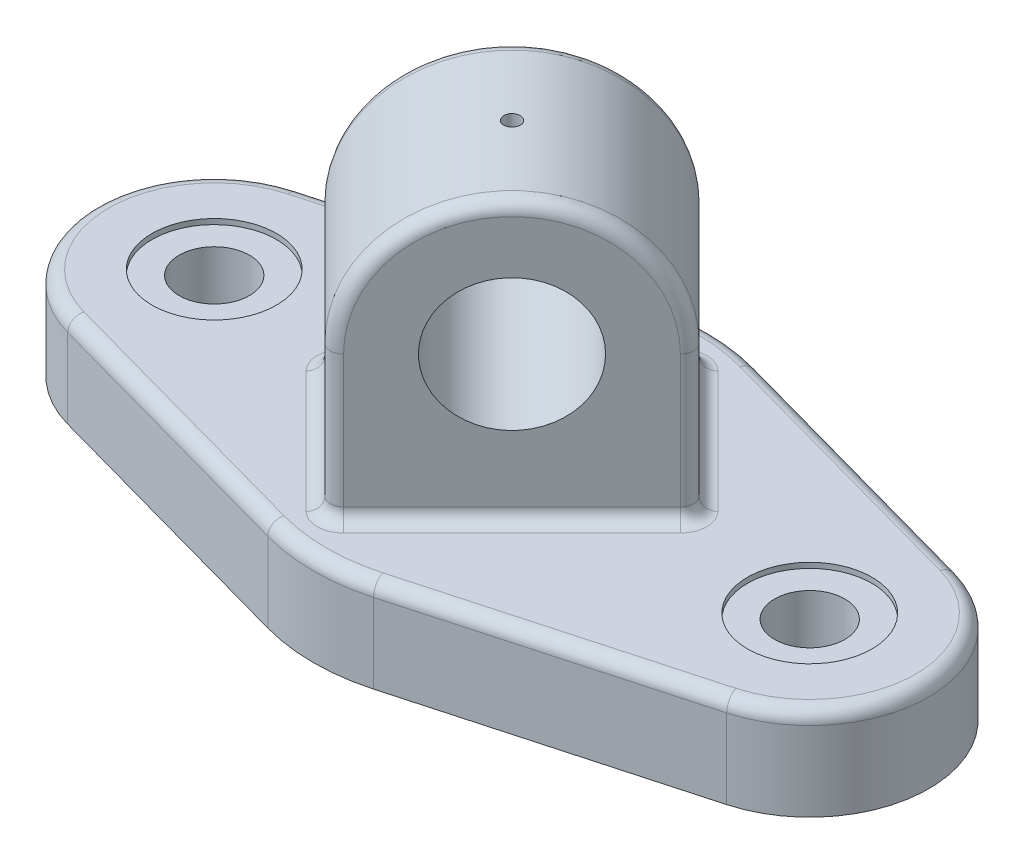
from build123d import *

# Parameters (mm, degrees)
BOSS_EXTRUDE1_DEPTH                                 = 17.78
CBORE_FOR_00_BINDING_HEAD_MACHINE_SCREW_D           = 13.4874
CBORE_FOR_00_BINDING_HEAD_MACHINE_SCREW_CBORE_D     = 23.876
CBORE_FOR_00_BINDING_HEAD_MACHINE_SCREW_CBORE_DEPTH = 1.016
SKETCH4_R                                           = 12.7
BOSS_EXTRUDE2_DEPTH                                 = 19.05
F_1_8_0_125_DIAMETER_HOLE1_REACH                    = 115.628
F_1_8_0_125_DIAMETER_HOLE1_BORE_R                   = 1.5875
FILLET1_R                                           = 2.54


with BuildPart() as part:
    # Sketch1 → Boss-Extrude1 (new body)
    with BuildSketch(Plane(origin=(0, 0, 0), x_dir=(1, 0, 0), z_dir=(0, 1, 0))):
        with BuildLine():
            Line((63.246, 22.032212417), (10.16, 36.720354029))
            ThreePointArc((10.16, 36.720354029), (0, 38.1), (-10.16, 36.720354029))
            Line((-10.16, 36.720354029), (-63.246, 22.032212417))
            ThreePointArc((-63.246, 22.032212417), (-80.01, 0), (-63.246, -22.032212417))
            Line((-63.246, -22.032212417), (-10.16, -36.720354029))
            ThreePointArc((-10.16, -36.720354029), (0, -38.1), (10.16, -36.720354029))
            Line((10.16, -36.720354029), (63.246, -22.032212417))
            ThreePointArc((63.246, -22.032212417), (80.01, 0), (63.246, 22.032212417))
        make_face()
    extrude(amount=BOSS_EXTRUDE1_DEPTH)

    # CBORE for _00 Binding Head Machine Screw (through all)
    with Locations(Plane(origin=(0, 17.78, 0), x_dir=(1, 0, 0), z_dir=(0, 1, 0))):
        with Locations((-57.15, 0), (57.15, 0)):
            CounterBoreHole(CBORE_FOR_00_BINDING_HEAD_MACHINE_SCREW_D / 2, CBORE_FOR_00_BINDING_HEAD_MACHINE_SCREW_CBORE_D / 2, CBORE_FOR_00_BINDING_HEAD_MACHINE_SCREW_CBORE_DEPTH)

    # Sketch4 → Boss-Extrude2 (add, symmetric)
    with BuildSketch(Plane(origin=(0, 0, 0), x_dir=(0, -1, 0), z_dir=(0.7071067811865464, 0, 0.7071067811865488))):
        with BuildLine():
            Line((-45.72, 25.4), (-15.24, 25.4))
            Line((-15.24, 25.4), (-15.24, -25.4))
            Line((-15.24, -25.4), (-45.72, -25.4))
            ThreePointArc((-45.72, -25.4), (-71.12, 0), (-45.72, 25.4))
        make_face()
        with Locations(Location((-45.72, 0, 0), (0, 0, 90))):
            Circle(SKETCH4_R, mode=Mode.SUBTRACT)
    extrude(amount=BOSS_EXTRUDE2_DEPTH, both=True)

    # 1_8 _0.125_ Diameter Hole1 bore (on position points) → 1_8 _0.125_ Diameter Hole1 (cut, up to next)
    with BuildSketch(Plane.ZX.offset(71.12), mode=Mode.PRIVATE) as f_1_8_0_125_diameter_hole1_sk1:
        Circle(F_1_8_0_125_DIAMETER_HOLE1_BORE_R)
    f_1_8_0_125_diameter_hole1_tool1 = extrude(f_1_8_0_125_diameter_hole1_sk1.sketch, amount=-F_1_8_0_125_DIAMETER_HOLE1_REACH, mode=Mode.PRIVATE) & part.part
    add(f_1_8_0_125_diameter_hole1_tool1.solids().sort_by_distance((0, 71.12, 0))[0], mode=Mode.SUBTRACT)

    # Fillet1
    fillet1_edges = [part.edges().sort_by_distance(p)[0] for p in [
        (0, 17.78, -38.1),
        (-36.703, 17.78, -29.376283223),
        (-80.01, 17.78, 0),
        (-36.703, 17.78, 29.376283223),
        (0, 17.78, 38.1),
        (36.703, 17.78, 29.376283223),
        (80.01, 17.78, 0),
        (17.960512242, 17.78, -17.960512242),
        (-13.470384182, 17.78, -13.470384182),
        (13.470384182, 17.78, 13.470384182),
        (-17.960512242, 17.78, 17.960512242),
        (-4.490128061, 31.75, 31.430896424),
        (31.430896424, 31.75, -4.490128061),
        (13.470384182, 71.12, 13.470384182),
        (-13.470384182, 71.12, -13.470384182),
        (-31.430896424, 31.75, 4.490128061),
        (4.490128061, 31.75, -31.430896424),
        (36.703, 17.78, -29.376283223),
    ]]
    fillet(fillet1_edges, radius=FILLET1_R)


solid = part.part
